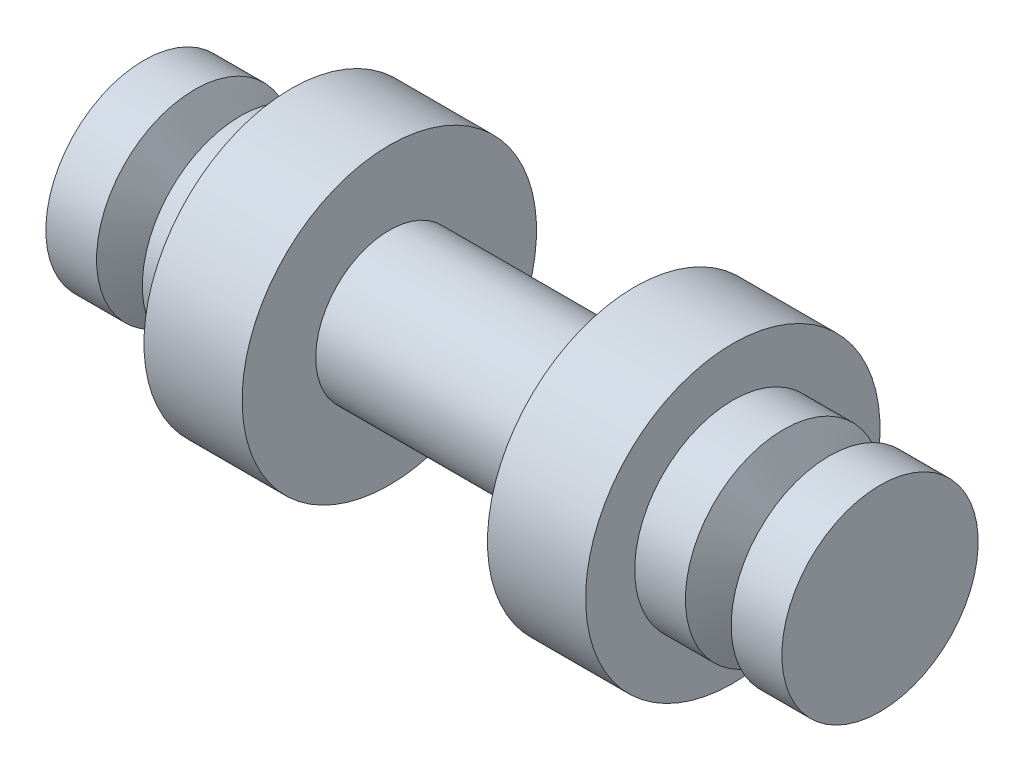
from build123d import *


with BuildPart() as part:
    # 스케치1 → 회전1 (revolve)
    with BuildSketch(Plane.XY):
        Polygon((25, 15), (-25, 15), (-25, 30), (-45, 30), (-45, 20), (-55.336923418, 20), (-60, 10), (-64.663076582, 20), (-75, 20), (-75, 0), (75, 0), (75, 20), (64.663076582, 20), (60, 10), (55.336923418, 20), (45, 20), (45, 30), (25, 30), align=None)
    revolve(axis=Axis((-75, 0, 0), (1, 0, 0)))


solid = part.part
